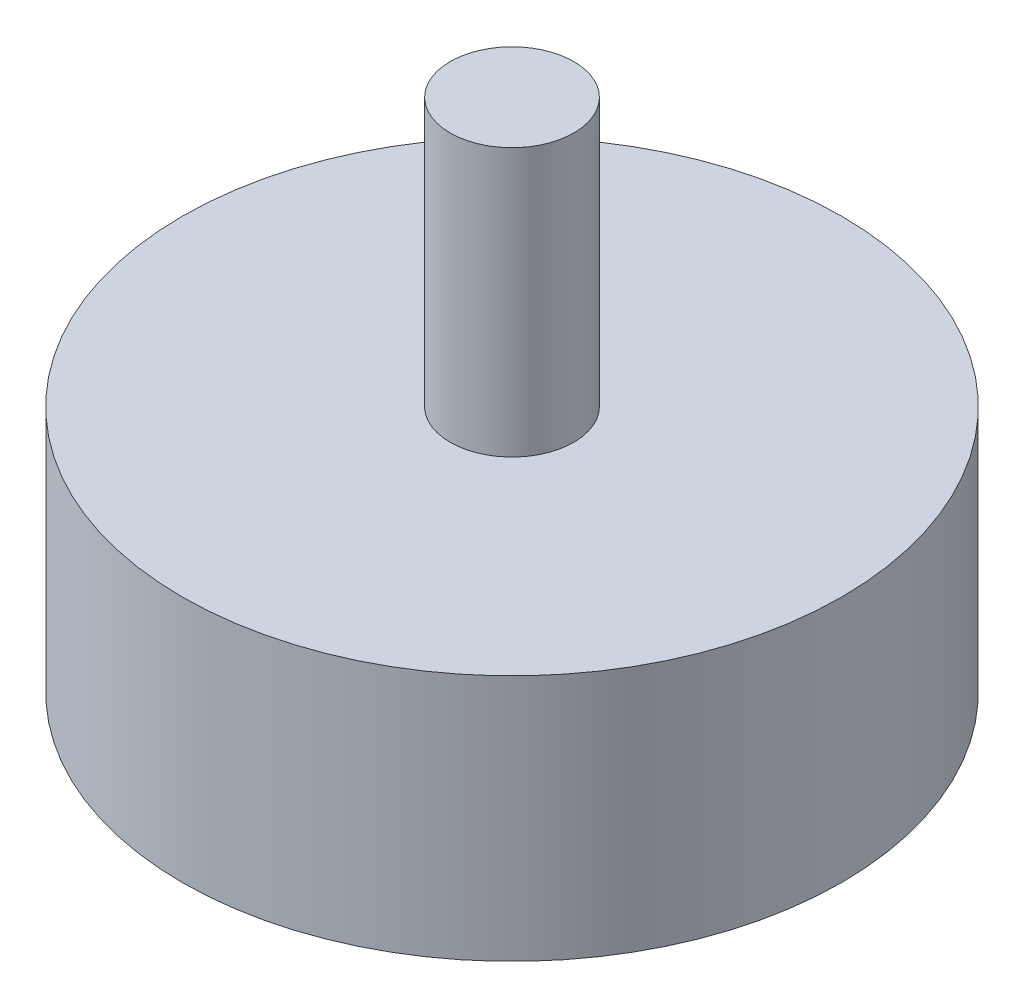
from build123d import *

# Parameters (mm, degrees)
SKETCH1_R           = 25.4
BOSS_EXTRUDE1_DEPTH = 9.525
SKETCH2_R           = 4.7625
BOSS_EXTRUDE2_DEPTH = 20.6375
SKETCH3_R           = 4.7625
CUT_EXTRUDE1_DEPTH  = 7.9375


with BuildPart() as part:
    # Sketch1 → Boss-Extrude1 (new body, symmetric)
    with BuildSketch(Plane(origin=(0, 0, 0), x_dir=(1, 0, 0), z_dir=(0, 1, 0))):
        Circle(SKETCH1_R)
    extrude(amount=BOSS_EXTRUDE1_DEPTH, both=True)

    # Sketch2 → Boss-Extrude2 (add)
    with BuildSketch(Plane(origin=(0, 9.525, 0), x_dir=(1, 0, 0), z_dir=(0, 1, 0))):
        Circle(SKETCH2_R)
    boss_extrude2 = extrude(amount=BOSS_EXTRUDE2_DEPTH)

    # Mirror1: Boss-Extrude2 across plane
    add(boss_extrude2.mirror(Plane.ZX))

    # Sketch3 → Cut-Extrude1 (cut)
    with BuildSketch(Plane(origin=(0, -30.1625, 0), x_dir=(-1, 0, 0), z_dir=(0, -1, 0))):
        Circle(SKETCH3_R)
    extrude(amount=-CUT_EXTRUDE1_DEPTH, mode=Mode.SUBTRACT)


solid = part.part
